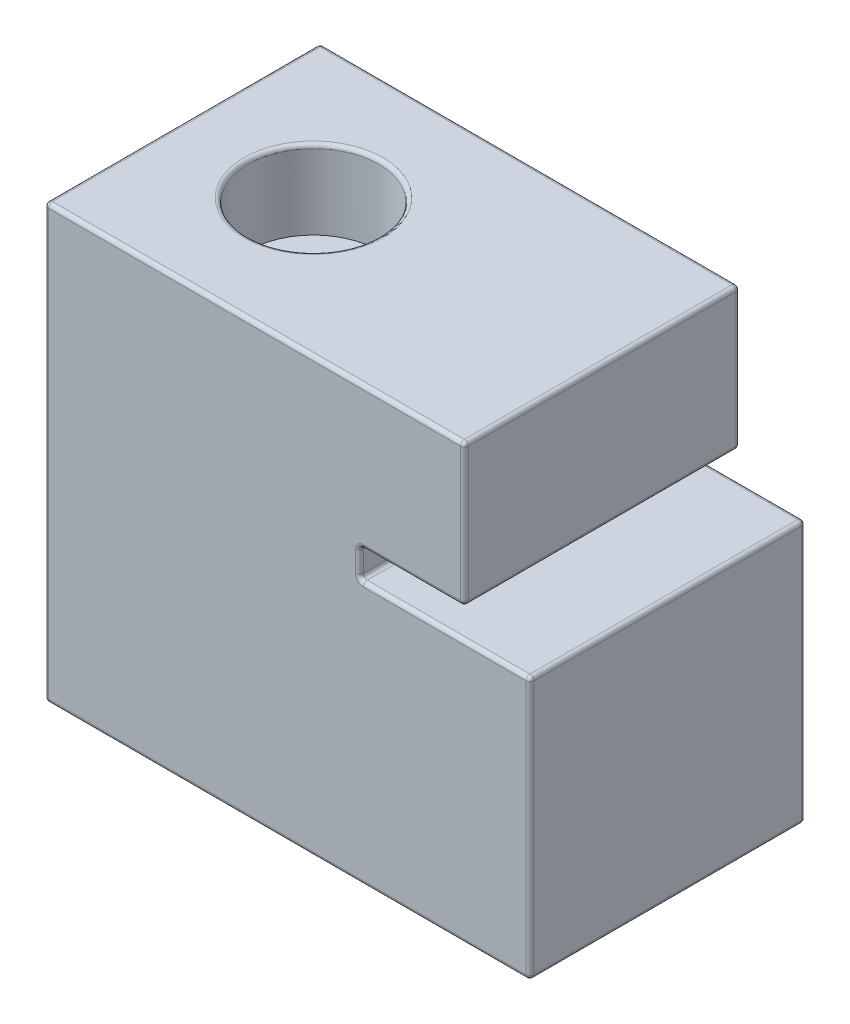
from build123d import *

# Parameters (mm, degrees)
BOSS_EXTRUDE1_DEPTH = 21
SKETCH2_R           = 2.65
CUT_EXTRUDE1_DEPTH  = 34
SKETCH3_R           = 5
CUT_EXTRUDE2_DEPTH  = 6
FILLET1_R           = 0.3


with BuildPart() as part:
    # Sketch1 → Boss-Extrude1 (new body)
    with BuildSketch(Plane.XY):
        Polygon((32, 33), (32, 22.2), (24, 22.2), (24, 20), (37, 20), (37, 0), (0, 0), (0, 33), align=None)
    extrude(amount=BOSS_EXTRUDE1_DEPTH)

    # Sketch2 → Cut-Extrude1 (cut, through all)
    with BuildSketch(Plane(origin=(0, 33, 0), x_dir=(1, 0, 0), z_dir=(0, 1, 0))):
        with Locations((10, -10.5)):
            Circle(SKETCH2_R)
    extrude(amount=-CUT_EXTRUDE1_DEPTH, mode=Mode.SUBTRACT)

    # Sketch3 → Cut-Extrude2 (cut)
    with BuildSketch(Plane(origin=(0, 33, 0), x_dir=(1, 0, 0), z_dir=(0, 1, 0))):
        with Locations((10, -10.5)):
            Circle(SKETCH3_R)
    extrude(amount=-CUT_EXTRUDE2_DEPTH, mode=Mode.SUBTRACT)

    # Fillet1
    fillet1_edges = [part.edges().sort_by_distance(p)[0] for p in [
        (30.5, 20, 0),
        (37, 10, 0),
        (18.5, 0, 0),
        (0, 16.5, 0),
        (37, 10, 21),
        (0, 33, 10.5),
        (32, 33, 10.5),
        (32, 22.2, 10.5),
        (24, 22.2, 10.5),
        (24, 20, 10.5),
        (37, 20, 10.5),
        (37, 0, 10.5),
        (0, 0, 10.5),
        (30.5, 20, 21),
        (24, 21.1, 21),
        (28, 22.2, 21),
        (7.35, 0, 10.5),
        (32, 27.6, 21),
        (5, 33, 10.5),
        (16, 33, 21),
        (0, 16.5, 21),
        (16, 33, 0),
        (18.5, 0, 21),
        (32, 27.6, 0),
        (28, 22.2, 0),
        (24, 21.1, 0),
    ]]
    fillet(fillet1_edges, radius=FILLET1_R)


solid = part.part
